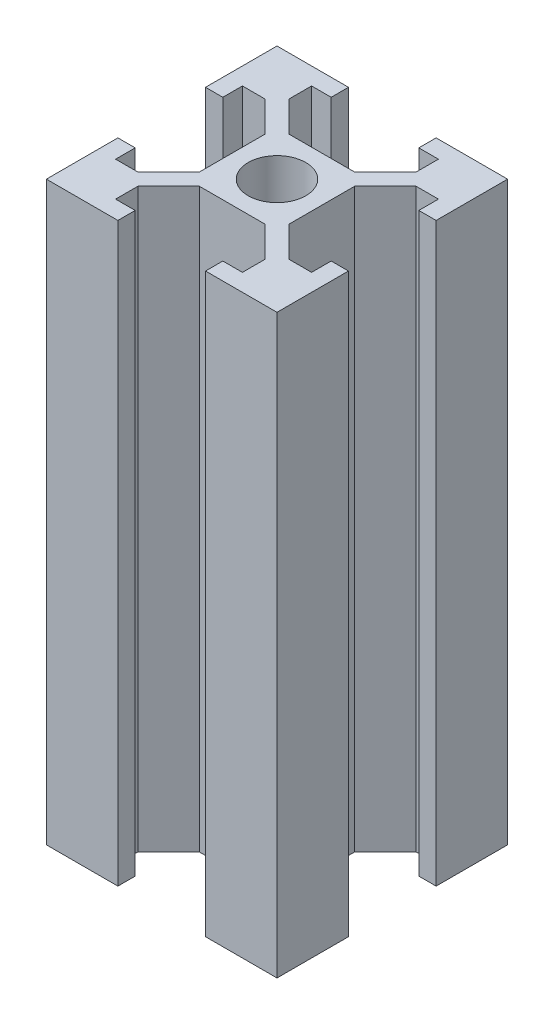
from build123d import *

# Parameters (mm, degrees)
SKETCH_1_W      = 1.5
SKETCH_1_H      = 1.7
SKETCH_1_W_2    = 1.7
SKETCH_1_H_2    = 1.5
SKETCH_1_W_3    = 7.8
SKETCH_1_H_3    = 7.8
SKETCH_1_R      = 2.5
EXTRUDE_1_DEPTH = 50


with BuildPart() as part:
    # 草图1 → 凸台-拉伸1 (new body)
    with BuildSketch(Plane(origin=(0, 0, 0), x_dir=(1, 0, 0), z_dir=(0, 1, 0))):
        Polygon((5.5, 8.5), (5.5, 6.560660172), (5.5, 5.5), (6.560660172, 5.5), (8.5, 5.5), (10, 5.5), (10, 10), (5.5, 10), align=None)
        with Locations((9.25, 4.65)):
            Rectangle(SKETCH_1_W, SKETCH_1_H)
        Polygon((5.5, 6.560660172), (2.839339828, 3.9), (3.9, 3.9), (3.9, 2.839339828), (6.560660172, 5.5), (5.5, 5.5), align=None)
        with Locations((4.65, 9.25)):
            Rectangle(SKETCH_1_W_2, SKETCH_1_H_2)
        Rectangle(SKETCH_1_W_3, SKETCH_1_H_3)
        Circle(SKETCH_1_R, mode=Mode.SUBTRACT)
        with Locations((-4.65, 9.25)):
            Rectangle(SKETCH_1_W_2, SKETCH_1_H_2)
        Polygon((-8.5, 5.5), (-6.560660172, 5.5), (-5.5, 5.5), (-5.5, 6.560660172), (-5.5, 8.5), (-5.5, 10), (-10, 10), (-10, 5.5), align=None)
        with Locations((-9.25, 4.65)):
            Rectangle(SKETCH_1_W, SKETCH_1_H)
        Polygon((-5.5, 5.5), (-6.560660172, 5.5), (-3.9, 2.839339828), (-3.9, 3.9), (-2.839339828, 3.9), (-5.5, 6.560660172), align=None)
        Polygon((-5.5, -5.5), (-6.560660172, -5.5), (-8.5, -5.5), (-10, -5.5), (-10, -10), (-5.5, -10), (-5.5, -8.5), (-5.5, -6.560660172), align=None)
        with Locations((-4.65, -9.25)):
            Rectangle(SKETCH_1_W_2, SKETCH_1_H_2)
        with Locations((-9.25, -4.65)):
            Rectangle(SKETCH_1_W, SKETCH_1_H)
        Polygon((-3.9, -3.9), (-3.9, -2.839339828), (-6.560660172, -5.5), (-5.5, -5.5), (-5.5, -6.560660172), (-2.839339828, -3.9), align=None)
        Polygon((3.9, -3.9), (2.839339828, -3.9), (5.5, -6.560660172), (5.5, -5.5), (6.560660172, -5.5), (3.9, -2.839339828), align=None)
        Polygon((5.5, -5.5), (5.5, -6.560660172), (5.5, -8.5), (5.5, -10), (10, -10), (10, -5.5), (8.5, -5.5), (6.560660172, -5.5), align=None)
        with Locations((9.25, -4.65)):
            Rectangle(SKETCH_1_W, SKETCH_1_H)
        with Locations((4.65, -9.25)):
            Rectangle(SKETCH_1_W_2, SKETCH_1_H_2)
    extrude(amount=EXTRUDE_1_DEPTH)


solid = part.part
